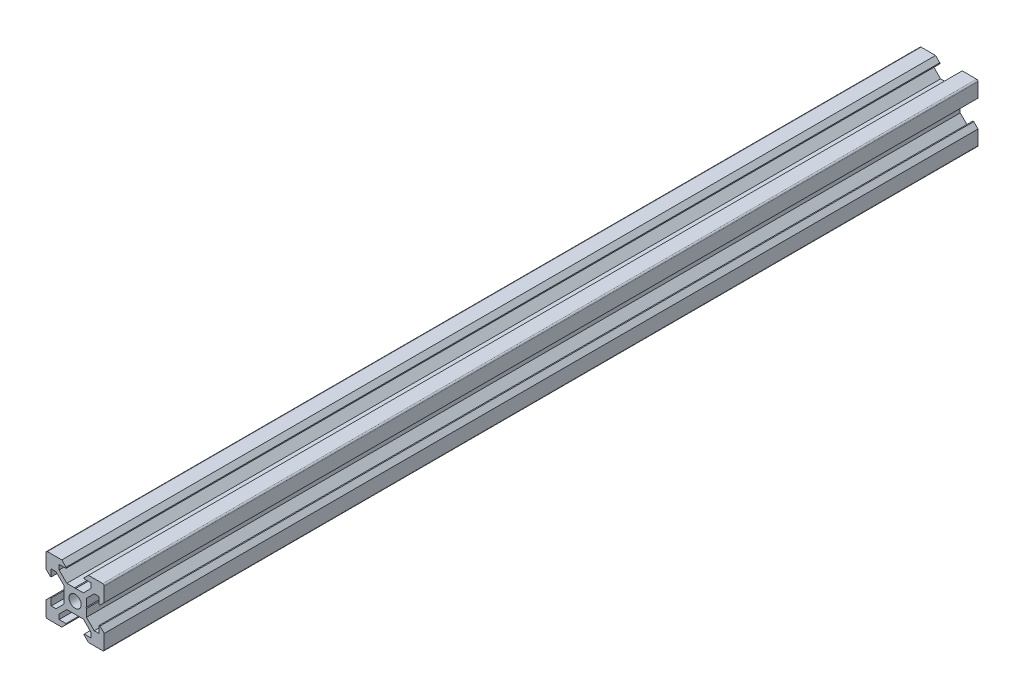
from build123d import *

# Parameters (mm, degrees)
SKETCH1_R           = 2.1
BOSS_EXTRUDE1_DEPTH = 300


with BuildPart() as part:
    # Sketch1 → Boss-Extrude1 (new body)
    with BuildSketch(Plane.XY):
        with BuildLine():
            Line((4.58, -10), (9.5, -10))
            ThreePointArc((9.5, -10), (9.853553391, -9.853553391), (10, -9.5))
            Line((10, -9.5), (10, -4.58))
            Line((10, -4.58), (8.545, -3.125))
            Line((8.545, -3.125), (8.2, -3.125))
            Line((8.2, -3.125), (8.2, -5.5))
            Line((8.2, -5.5), (6.560660172, -5.5))
            Line((6.560660172, -5.5), (3.9, -2.839339828))
            Line((3.9, -2.839339828), (3.9, -0.21))
            Line((3.9, -0.21), (3.69, 0))
            Line((3.69, 0), (3.9, 0.21))
            Line((3.9, 0.21), (3.9, 2.839339828))
            Line((3.9, 2.839339828), (6.560660172, 5.5))
            Line((6.560660172, 5.5), (8.2, 5.5))
            Line((8.2, 5.5), (8.2, 3.125))
            Line((8.2, 3.125), (8.545, 3.125))
            Line((8.545, 3.125), (10, 4.58))
            Line((10, 4.58), (10, 9.5))
            ThreePointArc((10, 9.5), (9.853553391, 9.853553391), (9.5, 10))
            Line((9.5, 10), (4.58, 10))
            Line((4.58, 10), (3.125, 8.545))
            Line((3.125, 8.545), (3.125, 8.2))
            Line((3.125, 8.2), (5.5, 8.2))
            Line((5.5, 8.2), (5.5, 6.560660172))
            Line((5.5, 6.560660172), (2.839339828, 3.9))
            Line((2.839339828, 3.9), (0.21, 3.9))
            Line((0.21, 3.9), (0, 3.69))
            Line((0, 3.69), (-0.21, 3.9))
            Line((-0.21, 3.9), (-2.839339828, 3.9))
            Line((-2.839339828, 3.9), (-5.5, 6.560660172))
            Line((-5.5, 6.560660172), (-5.5, 8.2))
            Line((-5.5, 8.2), (-3.125, 8.2))
            Line((-3.125, 8.2), (-3.125, 8.545))
            Line((-3.125, 8.545), (-4.58, 10))
            Line((-4.58, 10), (-9.5, 10))
            ThreePointArc((-9.5, 10), (-9.853553391, 9.853553391), (-10, 9.5))
            Line((-10, 9.5), (-10, 4.58))
            Line((-10, 4.58), (-8.545, 3.125))
            Line((-8.545, 3.125), (-8.2, 3.125))
            Line((-8.2, 3.125), (-8.2, 5.5))
            Line((-8.2, 5.5), (-6.560660172, 5.5))
            Line((-6.560660172, 5.5), (-3.9, 2.839339828))
            Line((-3.9, 2.839339828), (-3.9, 0.21))
            Line((-3.9, 0.21), (-3.69, 0))
            Line((-3.69, 0), (-3.9, -0.21))
            Line((-3.9, -0.21), (-3.9, -2.839339828))
            Line((-3.9, -2.839339828), (-6.560660172, -5.5))
            Line((-6.560660172, -5.5), (-8.2, -5.5))
            Line((-8.2, -5.5), (-8.2, -3.125))
            Line((-8.2, -3.125), (-8.545, -3.125))
            Line((-8.545, -3.125), (-10, -4.58))
            Line((-10, -4.58), (-10, -9.5))
            ThreePointArc((-10, -9.5), (-9.853553391, -9.853553391), (-9.5, -10))
            Line((-9.5, -10), (-4.58, -10))
            Line((-4.58, -10), (-3.125, -8.545))
            Line((-3.125, -8.545), (-3.125, -8.2))
            Line((-3.125, -8.2), (-5.5, -8.2))
            Line((-5.5, -8.2), (-5.5, -6.560660172))
            Line((-5.5, -6.560660172), (-2.839339828, -3.9))
            Line((-2.839339828, -3.9), (-0.21, -3.9))
            Line((-0.21, -3.9), (0, -3.69))
            Line((0, -3.69), (0.21, -3.9))
            Line((0.21, -3.9), (2.839339828, -3.9))
            Line((2.839339828, -3.9), (5.5, -6.560660172))
            Line((5.5, -6.560660172), (5.5, -8.2))
            Line((5.5, -8.2), (3.125, -8.2))
            Line((3.125, -8.2), (3.125, -8.545))
            Line((3.125, -8.545), (4.58, -10))
        make_face()
        Circle(SKETCH1_R, mode=Mode.SUBTRACT)
    extrude(amount=BOSS_EXTRUDE1_DEPTH)


solid = part.part
